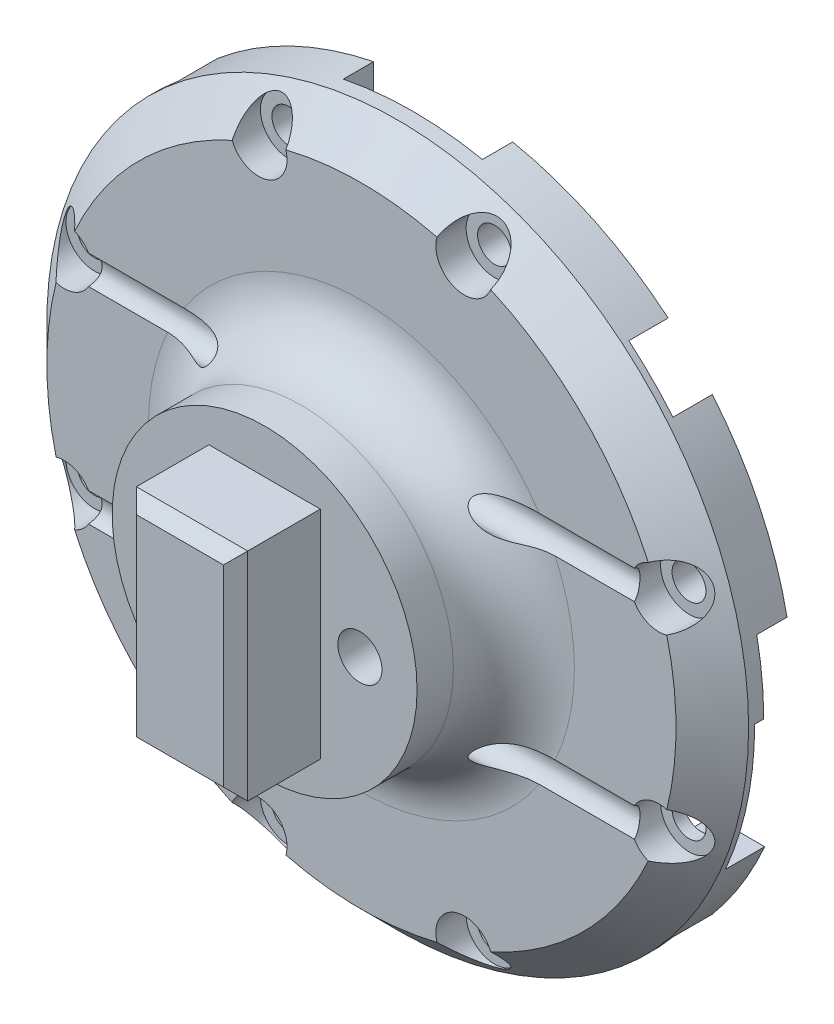
from build123d import *

# Parameters (mm, degrees)
SKETCH1_R               = 29
BOSS_EXTRUDE1_DEPTH     = 6.75
SKETCH3_W               = 44.5
SKETCH3_H               = 44.5
CUT_EXTRUDE1_DEPTH      = 3.25
SKETCH4_R               = 12.6
BOSS_EXTRUDE2_DEPTH     = 8
FILLET1_R               = 5
SKETCH5_R               = 1.825
CUT_EXTRUDE2_DEPTH      = 15.75
SKETCH6_W               = 9.2
SKETCH6_H               = 17.9
BOSS_EXTRUDE3_DEPTH     = 7
CHAMFER1_SIZE           = 1
SKETCH7_R               = 3.25
CUT_EXTRUDE3_DEPTH      = 2.5
FILLET2_R               = 1.5
CHAMFER2_SIZE           = 3
SKETCH9_R               = 1.3
CUT_EXTRUDE5_DEPTH      = 30
CUT_EXTRUDE5_DEPTH_BACK = 30
SKETCH10_W              = 11.5
SKETCH10_H              = 12.03351403
SKETCH10_W_2            = 12.03351403
SKETCH10_H_2            = 11.5
CUT_EXTRUDE6_DEPTH      = 2.5
SKETCH11_R              = 1.4
CUT_EXTRUDE7_DEPTH      = 22.75
SKETCH12_R              = 2.35
CUT_EXTRUDE8_DEPTH      = 2.5
SKETCH13_W              = 6.5
SKETCH13_H              = 6.5
CUT_EXTRUDE9_DEPTH      = 2.25
CHAMFER5_SIZE           = 1
SKETCH14_W              = 15.887507813
SKETCH14_H              = 11.6
CUT_EXTRUDE10_DEPTH     = 3.25


with BuildPart() as part:
    # Sketch1 → Boss-Extrude1 (new body)
    with BuildSketch(Plane.XY):
        Circle(SKETCH1_R)
    extrude(amount=BOSS_EXTRUDE1_DEPTH)

    # Sketch3 → Cut-Extrude1 (cut)
    with BuildSketch(Plane(origin=(0, 0, 0), x_dir=(-1, 0, 0), z_dir=(0, 0, -1))):
        Rectangle(SKETCH3_W, SKETCH3_H)
    extrude(amount=-CUT_EXTRUDE1_DEPTH, mode=Mode.SUBTRACT)

    # Sketch4 → Boss-Extrude2 (add)
    with BuildSketch(Plane.XY.offset(6.75)):
        Circle(SKETCH4_R)
    extrude(amount=BOSS_EXTRUDE2_DEPTH)

    # Fillet1
    fillet1_edges = [part.edges().sort_by_distance(p)[0] for p in [
        (-12.6, 0, 6.75),
    ]]
    fillet(fillet1_edges, radius=FILLET1_R)

    # Sketch5 → Cut-Extrude2 (cut, through all)
    with BuildSketch(Plane.XY.offset(14.75)):
        with Locations((-7.875, 0)):
            Circle(SKETCH5_R)
        with Locations((7.875, 0)):
            Circle(SKETCH5_R)
    extrude(amount=-CUT_EXTRUDE2_DEPTH, mode=Mode.SUBTRACT)

    # Sketch6 → Boss-Extrude3 (add)
    with BuildSketch(Plane.XY.offset(14.75)):
        Rectangle(SKETCH6_W, SKETCH6_H)
    extrude(amount=BOSS_EXTRUDE3_DEPTH)

    # Chamfer1
    chamfer1_edges = [part.edges().sort_by_distance(p)[0] for p in [
        (4.6, 0, 21.75),
        (0, 8.95, 21.75),
        (-4.6, 0, 21.75),
        (0, -8.95, 21.75),
    ]]
    chamfer(chamfer1_edges, length=CHAMFER1_SIZE)

    # Sketch7 → Cut-Extrude3 (cut)
    with BuildSketch(Plane(origin=(0, 0, 3.25), x_dir=(-1, 0, 0), z_dir=(0, 0, -1))):
        with Locations((-7.875, 0)):
            Circle(SKETCH7_R)
        with Locations((7.875, 0)):
            Circle(SKETCH7_R)
    extrude(amount=-CUT_EXTRUDE3_DEPTH, mode=Mode.SUBTRACT)

    # Fillet2
    fillet2_edges = [part.edges().sort_by_distance(p)[0] for p in [
        (11.125, 0, 3.25),
        (-4.625, 0, 3.25),
    ]]
    fillet(fillet2_edges, radius=FILLET2_R)

    # Chamfer2
    chamfer2_edges = [part.edges().sort_by_distance(p)[0] for p in [
        (-29, 0, 6.75),
    ]]
    chamfer(chamfer2_edges, length=CHAMFER2_SIZE)

    # Sketch9 → Cut-Extrude5 (cut, two sides)
    with BuildSketch(Plane(origin=(0, 0, 0), x_dir=(0, 0, -1), z_dir=(1, 0, 0))) as cut_extrude5_sk:
        with Locations((-7.25, 8.5)):
            Circle(SKETCH9_R)
        with Locations((-7.25, -8.5)):
            Circle(SKETCH9_R)
    extrude(amount=CUT_EXTRUDE5_DEPTH, mode=Mode.SUBTRACT)
    extrude(cut_extrude5_sk.sketch, amount=-CUT_EXTRUDE5_DEPTH_BACK, mode=Mode.SUBTRACT)

    # Sketch10 → Cut-Extrude6 (cut)
    with BuildSketch(Plane(origin=(0, 0, 0), x_dir=(-1, 0, 0), z_dir=(0, 0, -1))):
        with Locations((0, -28.01742408)):
            Rectangle(SKETCH10_W, SKETCH10_H)
        with Locations((28.01742408, 0)):
            Rectangle(SKETCH10_W_2, SKETCH10_H_2)
        with Locations((-28.01742408, 0)):
            Rectangle(SKETCH10_W_2, SKETCH10_H_2)
        with Locations((0, 28.01742408)):
            Rectangle(SKETCH10_W, SKETCH10_H)
    extrude(amount=-CUT_EXTRUDE6_DEPTH, mode=Mode.SUBTRACT)

    # Sketch11 → Cut-Extrude7 (cut, through all)
    with BuildSketch(Plane(origin=(0, 0, 0), x_dir=(-1, 0, 0), z_dir=(0, 0, -1))):
        with Locations((-24.571324751, 8.5)):
            Circle(SKETCH11_R)
        with Locations((-24.571324751, -8.5)):
            Circle(SKETCH11_R)
        with Locations((-8.5, 24.571324751)):
            Circle(SKETCH11_R)
        with Locations((8.5, 24.571324751)):
            Circle(SKETCH11_R)
        with Locations((24.571324751, 8.5)):
            Circle(SKETCH11_R)
        with Locations((24.571324751, -8.5)):
            Circle(SKETCH11_R)
        with Locations((8.5, -24.571324751)):
            Circle(SKETCH11_R)
        with Locations((-8.5, -24.571324751)):
            Circle(SKETCH11_R)
    extrude(amount=-CUT_EXTRUDE7_DEPTH, mode=Mode.SUBTRACT)

    # Sketch12 → Cut-Extrude8 (cut)
    with BuildSketch(Plane.XY.offset(6.75)):
        with Locations((-24.571324751, 8.5)):
            Circle(SKETCH12_R)
        with Locations((-24.571324751, -8.5)):
            Circle(SKETCH12_R)
        with Locations((8.5, 24.571324751)):
            Circle(SKETCH12_R)
        with Locations((-8.5, 24.571324751)):
            Circle(SKETCH12_R)
        with Locations((24.571324751, -8.5)):
            Circle(SKETCH12_R)
        with Locations((24.571324751, 8.5)):
            Circle(SKETCH12_R)
        with Locations((-8.5, -24.571324751)):
            Circle(SKETCH12_R)
        with Locations((8.5, -24.571324751)):
            Circle(SKETCH12_R)
    extrude(amount=-CUT_EXTRUDE8_DEPTH, mode=Mode.SUBTRACT)

    # Sketch13 → Cut-Extrude9 (cut)
    with BuildSketch(Plane(origin=(0, 0, 3.25), x_dir=(-1, 0, 0), z_dir=(0, 0, -1))):
        with Locations((-18.9, 11.5)):
            Rectangle(SKETCH13_W, SKETCH13_H)
        with Locations((11.5, 18.9)):
            Rectangle(SKETCH13_W, SKETCH13_H)
        with Locations((18.9, -11.5)):
            Rectangle(SKETCH13_W, SKETCH13_H)
        with Locations((-11.5, -18.9)):
            Rectangle(SKETCH13_W, SKETCH13_H)
    extrude(amount=-CUT_EXTRUDE9_DEPTH, mode=Mode.SUBTRACT)

    # Chamfer5
    chamfer5_edges = [part.edges().sort_by_distance(p)[0] for p in [
        (18.9, 8.25, 3.25),
        (15.65, 11.5, 3.25),
        (18.9, 14.75, 3.25),
        (-8.25, 18.9, 3.25),
        (-11.5, 15.65, 3.25),
        (-14.75, 18.9, 3.25),
        (-18.9, -8.25, 3.25),
        (-15.65, -11.5, 3.25),
        (-18.9, -14.75, 3.25),
        (8.25, -18.9, 3.25),
        (11.5, -15.65, 3.25),
        (14.75, -18.9, 3.25),
    ]]
    chamfer(chamfer5_edges, length=CHAMFER5_SIZE)

    # Sketch14 → Cut-Extrude10 (cut)
    with BuildSketch(Plane(origin=(0, 0, 0), x_dir=(-1, 0, 0), z_dir=(0, 0, -1))):
        with Locations((-27.176000206, -5.8)):
            Rectangle(SKETCH14_W, SKETCH14_H)
    extrude(amount=-CUT_EXTRUDE10_DEPTH, mode=Mode.SUBTRACT)


solid = part.part
